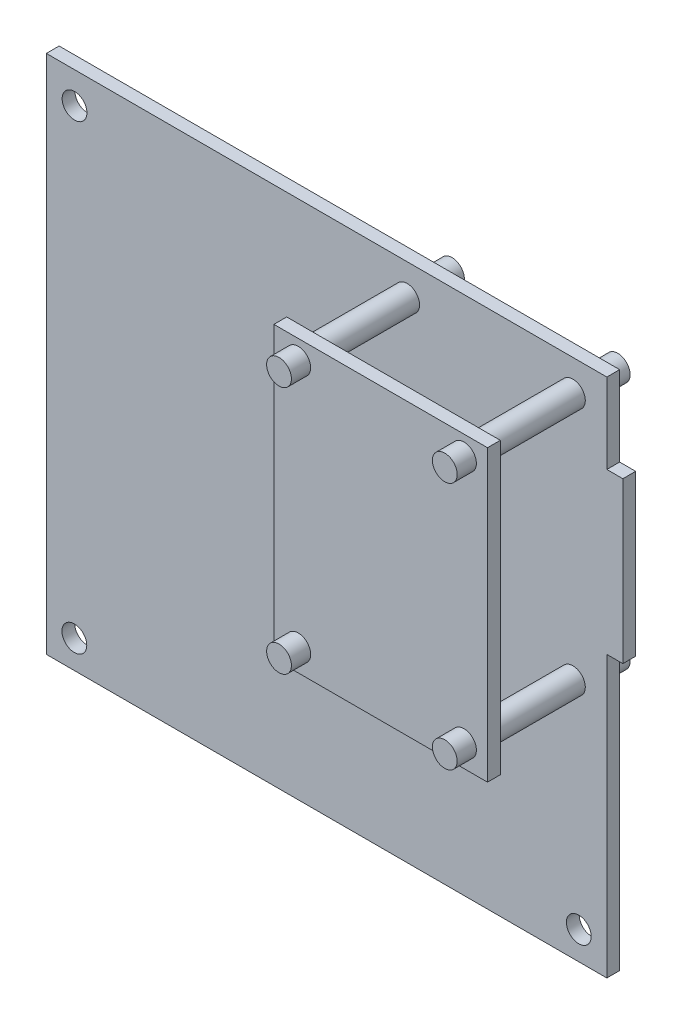
from build123d import *

# Parameters (mm, degrees)
SKETCH1_R             = 1.55
BOSS_EXTRUDE1_DEPTH   = 1.6
SKETCH1_3_R           = 1.55
BOSS_EXTRUDE2_DEPTH   = 4
BOSS_EXTRUDE2_2_DEPTH = 4
BOSS_EXTRUDE2_3_DEPTH = 4
BOSS_EXTRUDE2_4_DEPTH = 4
SKETCH1_4_R           = 1.55
BOSS_EXTRUDE3_DEPTH   = 17.6
BOSS_EXTRUDE4_START   = 12
SKETCH2_W             = 26.677983171
SKETCH2_H             = 36.175587157
BOSS_EXTRUDE4_DEPTH   = 1.6


with BuildPart() as part:
    # Sketch1 → Boss-Extrude1 (new body)
    with BuildSketch(Plane.XY):
        Polygon((70, 55), (70, 65), (0, 65), (0, 0), (70, 0), (70, 35), (72, 35), (72, 55), align=None)
        with Locations((3.523, 61.1)):
            Circle(SKETCH1_R, mode=Mode.SUBTRACT)
        with Locations((3.5, 3.5)):
            Circle(SKETCH1_R, mode=Mode.SUBTRACT)
        with Locations((66.5, 3.5)):
            Circle(SKETCH1_R, mode=Mode.SUBTRACT)
        with Locations((45.06, 61.1)):
            Circle(SKETCH1_R, mode=Mode.SUBTRACT)
        with Locations((65.76, 61.1)):
            Circle(SKETCH1_R, mode=Mode.SUBTRACT)
        with Locations((45.06, 30.1)):
            Circle(SKETCH1_R, mode=Mode.SUBTRACT)
        with Locations((65.76, 30.1)):
            Circle(SKETCH1_R, mode=Mode.SUBTRACT)
    extrude(amount=BOSS_EXTRUDE1_DEPTH)



with BuildPart() as body_2:
    # Sketch1_3 → Boss-Extrude2 (new body)
    with BuildSketch(Plane.XY):
        with Locations((45.06, 61.1)):
            Circle(SKETCH1_3_R)
    extrude(amount=-BOSS_EXTRUDE2_DEPTH)


with BuildPart() as body_3:
    # Sketch1_3 → Boss-Extrude2 2 (new body)
    with BuildSketch(Plane.XY):
        with Locations((65.76, 61.1)):
            Circle(SKETCH1_3_R)
    extrude(amount=-BOSS_EXTRUDE2_2_DEPTH)


with BuildPart() as body_4:
    # Sketch1_3 → Boss-Extrude2 3 (new body)
    with BuildSketch(Plane.XY):
        with Locations((45.06, 30.1)):
            Circle(SKETCH1_3_R)
    extrude(amount=-BOSS_EXTRUDE2_3_DEPTH)


with BuildPart() as body_5:
    # Sketch1_3 → Boss-Extrude2 4 (new body)
    with BuildSketch(Plane.XY):
        with Locations((65.76, 30.1)):
            Circle(SKETCH1_3_R)
    extrude(amount=-BOSS_EXTRUDE2_4_DEPTH)


with BuildPart() as part_1:
    add(part.part)

    add(body_2.part)  # Boss-Extrude3 merges body 2

    add(body_3.part)  # Boss-Extrude3 merges body 3

    add(body_4.part)  # Boss-Extrude3 merges body 4

    add(body_5.part)  # Boss-Extrude3 merges body 5
    # Sketch1_4 → Boss-Extrude3 (add)
    with BuildSketch(Plane.XY):
        with Locations((45.06, 61.1)):
            Circle(SKETCH1_4_R)
        with Locations((65.76, 61.1)):
            Circle(SKETCH1_4_R)
        with Locations((45.06, 30.1)):
            Circle(SKETCH1_4_R)
        with Locations((65.76, 30.1)):
            Circle(SKETCH1_4_R)
    extrude(amount=BOSS_EXTRUDE3_DEPTH)

    # Sketch2 → Boss-Extrude4 (add)
    with BuildSketch(Plane.XY.offset(1.6).offset(BOSS_EXTRUDE4_START)):
        with Locations((55.356329563, 45.415531536)):
            Rectangle(SKETCH2_W, SKETCH2_H)
    extrude(amount=BOSS_EXTRUDE4_DEPTH)


solid = part_1.part
